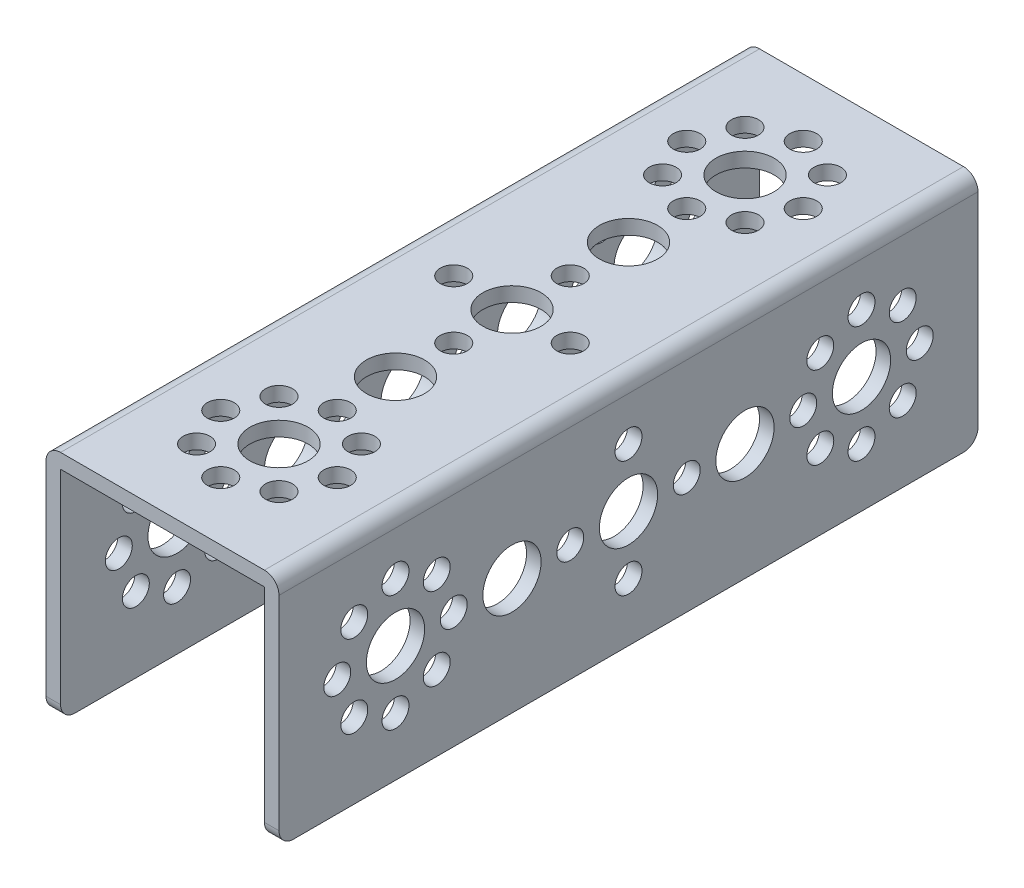
from build123d import *

# Parameters (mm, degrees)
BOSS_EXTRUDE1_DEPTH = 96
SKETCH2_R           = 4
SKETCH2_R_2         = 1.85
CUT_EXTRUDE1_DEPTH  = 33
SKETCH3_R           = 4
SKETCH3_R_2         = 1.85
CUT_EXTRUDE2_DEPTH  = 33
FILLET1_R           = 2


with BuildPart() as part:
    # Sketch1 → Boss-Extrude1 (new body)
    with BuildSketch(Plane.XY):
        Polygon((14, -16), (16, -16), (16, 16), (-16, 16), (-16, -16), (-14, -16), (-14, 14), (14, 14), align=None)
    extrude(amount=-BOSS_EXTRUDE1_DEPTH)

    # Sketch2 → Cut-Extrude1 (cut, through all)
    with BuildSketch(Plane(origin=(0, 16, 0), x_dir=(1, 0, 0), z_dir=(0, 1, 0))):
        with Locations((0, 32)):
            Circle(SKETCH2_R)
        with Locations((0, 64)):
            Circle(SKETCH2_R)
        with Locations((0, 48)):
            Circle(SKETCH2_R)
        with Locations((0, 56)):
            Circle(SKETCH2_R_2)
        with Locations((0, 40)):
            Circle(SKETCH2_R_2)
        with Locations((8, 48)):
            Circle(SKETCH2_R_2)
        with Locations((-8, 48)):
            Circle(SKETCH2_R_2)
        with Locations((0, 24)):
            Circle(SKETCH2_R_2)
        with Locations((8, 16)):
            Circle(SKETCH2_R_2)
        with Locations((0, 16)):
            Circle(SKETCH2_R)
        with Locations((-8, 16)):
            Circle(SKETCH2_R_2)
        with Locations((-5.66, 10.34)):
            Circle(SKETCH2_R_2)
        with Locations((5.66, 10.34)):
            Circle(SKETCH2_R_2)
        with Locations((0, 8)):
            Circle(SKETCH2_R_2)
        with Locations((-5.66, 21.66)):
            Circle(SKETCH2_R_2)
        with Locations((5.66, 21.66)):
            Circle(SKETCH2_R_2)
        with Locations((0, 88)):
            Circle(SKETCH2_R_2)
        with Locations((8, 80)):
            Circle(SKETCH2_R_2)
        with Locations((0, 80)):
            Circle(SKETCH2_R)
        with Locations((-8, 80)):
            Circle(SKETCH2_R_2)
        with Locations((-5.66, 74.34)):
            Circle(SKETCH2_R_2)
        with Locations((5.66, 74.34)):
            Circle(SKETCH2_R_2)
        with Locations((0, 72)):
            Circle(SKETCH2_R_2)
        with Locations((-5.66, 85.66)):
            Circle(SKETCH2_R_2)
        with Locations((5.66, 85.66)):
            Circle(SKETCH2_R_2)
    extrude(amount=-CUT_EXTRUDE1_DEPTH, mode=Mode.SUBTRACT)

    # Sketch3 → Cut-Extrude2 (cut, through all)
    with BuildSketch(Plane(origin=(16, 0, 0), x_dir=(0, 0, -1), z_dir=(1, 0, 0))):
        with Locations((64, 0)):
            Circle(SKETCH3_R)
        with Locations((32, 0)):
            Circle(SKETCH3_R)
        with Locations((48, 0)):
            Circle(SKETCH3_R)
        with Locations((40, 0)):
            Circle(SKETCH3_R_2)
        with Locations((56, 0)):
            Circle(SKETCH3_R_2)
        with Locations((48, 8)):
            Circle(SKETCH3_R_2)
        with Locations((48, -8)):
            Circle(SKETCH3_R_2)
        with Locations((72, 0)):
            Circle(SKETCH3_R_2)
        with Locations((80, 8)):
            Circle(SKETCH3_R_2)
        with Locations((80, 0)):
            Circle(SKETCH3_R)
        with Locations((80, -8)):
            Circle(SKETCH3_R_2)
        with Locations((85.66, -5.66)):
            Circle(SKETCH3_R_2)
        with Locations((85.66, 5.66)):
            Circle(SKETCH3_R_2)
        with Locations((88, 0)):
            Circle(SKETCH3_R_2)
        with Locations((74.34, -5.66)):
            Circle(SKETCH3_R_2)
        with Locations((74.34, 5.66)):
            Circle(SKETCH3_R_2)
        with Locations((8, 0)):
            Circle(SKETCH3_R_2)
        with Locations((16, 8)):
            Circle(SKETCH3_R_2)
        with Locations((16, 0)):
            Circle(SKETCH3_R)
        with Locations((16, -8)):
            Circle(SKETCH3_R_2)
        with Locations((21.66, -5.66)):
            Circle(SKETCH3_R_2)
        with Locations((21.66, 5.66)):
            Circle(SKETCH3_R_2)
        with Locations((24, 0)):
            Circle(SKETCH3_R_2)
        with Locations((10.34, -5.66)):
            Circle(SKETCH3_R_2)
        with Locations((10.34, 5.66)):
            Circle(SKETCH3_R_2)
    extrude(amount=-CUT_EXTRUDE2_DEPTH, mode=Mode.SUBTRACT)

    # Fillet1
    fillet1_edges = [part.edges().sort_by_distance(p)[0] for p in [
        (-15, -16, -96),
        (-16, 16, -48),
        (16, 16, -48),
        (15, -16, -96),
        (15, -16, 0),
        (-15, -16, 0),
    ]]
    fillet(fillet1_edges, radius=FILLET1_R)


solid = part.part
